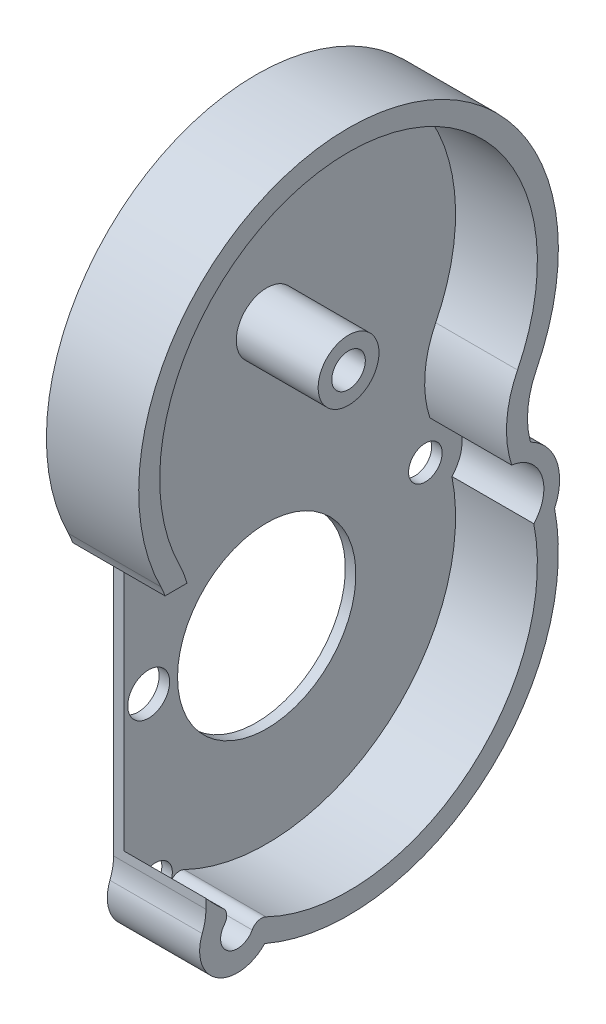
from build123d import *

# Parameters (mm, degrees)
BOSS_EXTRUDE1_DEPTH = 8.8
SKETCH1_3_R         = 1.9950000000003372
SKETCH1_3_R_2       = 8.499000000001052
SKETCH1_3_R_3       = 1.5999999999998604
SKETCH1_3_R_4       = 2.9000000000004036
BOSS_EXTRUDE2_DEPTH = 1
SKETCH1_4_R         = 2.9000000000004036
SKETCH1_4_R_2       = 1.5999999999998604
BOSS_EXTRUDE3_DEPTH = 8.8
FILLET1_R           = 1


with BuildPart() as part:
    # Sketch1 → Boss-Extrude1 (new body)
    with BuildSketch(Plane(origin=(-9277.020495484805, 0, 0), x_dir=(0, 0, -1), z_dir=(1, 0, 0))):
        with BuildLine():
            Line((-5181.361026538003, -2712.2298566105233), (-5181.361026538003, -2713.1295442369124))
            ThreePointArc((-5181.361026538003, -2713.1295442369124), (-5181.449009948379, -2714.0634034464592), (-5181.7098637473055, -2714.9643970087795))
            ThreePointArc((-5181.7098637473055, -2714.9643970087795), (-5180.298716040606, -2719.319524523044), (-5175.754002429446, -2718.7681156836497))
            ThreePointArc((-5175.754002429446, -2718.7681156836493), (-5155.268489112517, -2716.0470361610683), (-5148.125988175469, -2696.6551510028244))
            ThreePointArc((-5148.125988175468, -2696.6551510028244), (-5147.923825496746, -2692.8741534881237), (-5150.429715151682, -2690.0356100249855))
            ThreePointArc((-5150.429715151682, -2690.0356100249855), (-5150.672402006578, -2687.1467824336814), (-5149.869641086049, -2684.3611412747578))
            ThreePointArc((-5149.869641086049, -2684.3611412747578), (-5167.766026538003, -2655.432569846187), (-5185.662411989956, -2684.361141274758))
            ThreePointArc((-5185.662411989956, -2684.361141274758), (-5185.445898231984, -2684.832832292979), (-5185.260425515467, -2685.3175698461864))
            Line((-5185.2604255154665, -2685.3175698461864), (-5183.1689314111645, -2685.3175698461864))
            ThreePointArc((-5183.1689314111645, -2685.3175698461864), (-5183.475000193814, -2684.375475532257), (-5183.87277344476, -2683.4682841319004))
            ThreePointArc((-5183.872773444761, -2683.468284131901), (-5167.766026538003, -2657.432569846187), (-5151.659279631244, -2683.4682841319004))
            ThreePointArc((-5151.659279631244, -2683.4682841319004), (-5152.684326847257, -2687.2014849950892), (-5152.214633681771, -2691.0442572769534))
            ThreePointArc((-5152.214633681771, -2691.044257276954), (-5149.350375503743, -2693.339145363929), (-5150.110119114768, -2696.929866167285))
            ThreePointArc((-5150.110119114768, -2696.929866167285), (-5157.293990334202, -2715.0728040569593), (-5176.7849023498975, -2716.0101139109493))
            ThreePointArc((-5176.7849023498975, -2716.0101139109493), (-5179.250079105888, -2717.6157486981815), (-5178.709438757866, -2714.723886405067))
            ThreePointArc((-5178.709438757866, -2714.723886405067), (-5180.098441740306, -2713.544073775103), (-5181.361026538003, -2712.2298566105233))
        make_face()
    extrude(amount=BOSS_EXTRUDE1_DEPTH)

    # Sketch1_3 → Boss-Extrude2 (add)
    with BuildSketch(Plane(origin=(-9277.020495484805, 0, 0), x_dir=(0, 0, -1), z_dir=(1, 0, 0))):
        with BuildLine():
            Line((-5181.361026538003, -2685.3175698461864), (-5181.361026538003, -2712.2298566105233))
            ThreePointArc((-5181.361026538003, -2712.2298566105233), (-5180.098441740306, -2713.544073775103), (-5178.709438757866, -2714.723886405067))
            ThreePointArc((-5178.709438757866, -2714.723886405067), (-5177.471973970118, -2714.9552333108672), (-5176.7849023498975, -2716.0101139109493))
            ThreePointArc((-5176.7849023498975, -2716.0101139109493), (-5175.822472884072, -2716.5289567784425), (-5174.830317408971, -2716.98840852897))
            ThreePointArc((-5174.830317408971, -2716.98840852897), (-5156.424427633244, -2714.409984996477), (-5150.110119114768, -2696.929866167285))
            ThreePointArc((-5150.110119114768, -2696.929866167285), (-5149.350375503743, -2693.339145363929), (-5152.214633681771, -2691.044257276954))
            ThreePointArc((-5152.214633681771, -2691.0442572769534), (-5152.429634860403, -2690.2883766387154), (-5152.584616128909, -2689.5179469842446))
            ThreePointArc((-5152.584616128909, -2689.5179469842446), (-5152.596121525538, -2686.4205875195544), (-5151.659279631244, -2683.4682841319004))
            ThreePointArc((-5151.659279631244, -2683.4682841319004), (-5167.766026538003, -2657.432569846187), (-5183.872773444761, -2683.468284131901))
            ThreePointArc((-5183.87277344476, -2683.4682841319004), (-5183.475000193814, -2684.375475532257), (-5183.1689314111645, -2685.3175698461864))
            Line((-5183.1689314111645, -2685.3175698461864), (-5181.361026538003, -2685.3175698461864))
        make_face()
        with Locations(Location((-5179.016026538003, -2700.4325698461867, 0), (0, 0, 180))):
            Circle(SKETCH1_3_R, mode=Mode.SUBTRACT)
        with Locations(Location((-5167.766026538003, -2700.432569846186, 0), (0, 0, 180))):
            Circle(SKETCH1_3_R_2, mode=Mode.SUBTRACT)
        with Locations(Location((-5152.646026538003, -2694.5175698461867, 0), (0, 0, 180))):
            Circle(SKETCH1_3_R_3, mode=Mode.SUBTRACT)
        with Locations(Location((-5167.766026538003, -2675.4325698461867, 0), (0, 0, 180))):
            Circle(SKETCH1_3_R_4, mode=Mode.SUBTRACT)
    extrude(amount=BOSS_EXTRUDE2_DEPTH)

    # Sketch1_4 → Boss-Extrude3 (add)
    with BuildSketch(Plane(origin=(-9277.020495484805, 0, 0), x_dir=(0, 0, -1), z_dir=(1, 0, 0))):
        with Locations(Location((-5167.766026538003, -2675.4325698461867, 0), (0, 0, 180))):
            Circle(SKETCH1_4_R)
        with Locations((-5167.766026538003, -2675.4325698461867)):
            Circle(SKETCH1_4_R_2, mode=Mode.SUBTRACT)
    extrude(amount=BOSS_EXTRUDE3_DEPTH)

    # Fillet1
    fillet1_edges = [part.edges().sort_by_distance(p)[0] for p in [
        (-9272.120495484805, -2716.0101139109493, 5176.7849023498975),
        (-9272.120495484805, -2714.723886405067, 5178.709438757866),
    ]]
    fillet(fillet1_edges, radius=FILLET1_R)


solid = part.part
